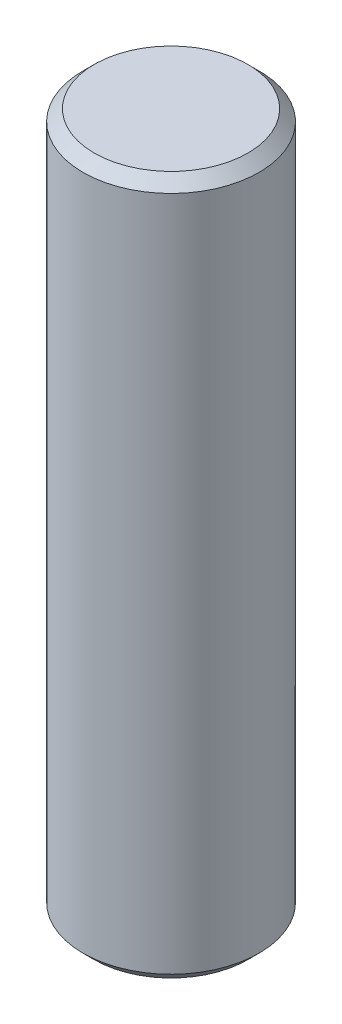
from build123d import *

# Parameters (mm, degrees)
SKETCH1_R           = 4
BOSS_EXTRUDE1_DEPTH = 31.75
CHAMFER1_SIZE       = 0.508


with BuildPart() as part:
    # Sketch1 → Boss-Extrude1 (new body)
    with BuildSketch(Plane(origin=(0, 0, 0), x_dir=(1, 0, 0), z_dir=(0, 1, 0))):
        Circle(SKETCH1_R)
    extrude(amount=BOSS_EXTRUDE1_DEPTH)

    # Chamfer1
    chamfer1_edges = [part.edges().sort_by_distance(p)[0] for p in [
        (-4, 0, 0),
        (-4, 31.75, 0),
    ]]
    chamfer(chamfer1_edges, length=CHAMFER1_SIZE)


solid = part.part
